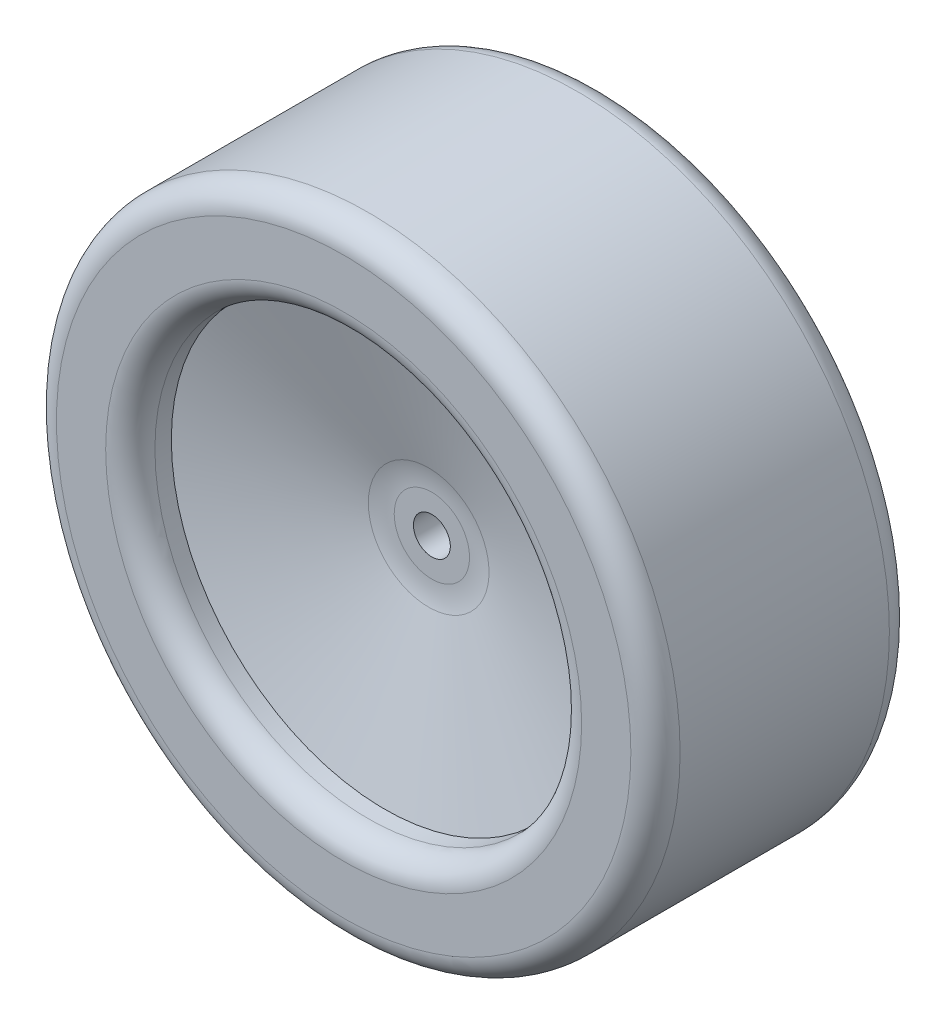
from build123d import *

# Parameters (mm, degrees)
CROQUIS2_R            = 2.25
CORTAR_EXTRUIR1_DEPTH = 21.75
REDONDEO1_R           = 3
REDONDEO2_R           = 10


with BuildPart() as part:
    # Croquis1 → Revolución4 (revolve)
    with BuildSketch(Plane(origin=(0, 0, 0), x_dir=(0, 0, -1), z_dir=(1, 0, 0))):
        Polygon((15.75, 38), (-15.75, 38), (-15.75, 26), (-10.75, 26), (-5, 6), (-5, 0), (5, 0), (5, 6), (10.75, 26), (15.75, 26), align=None)
    revolve(axis=Axis((0, 0, -5), (0, 0, 1)))

    # Croquis2 → Cortar-Extruir1 (cut, through all)
    with BuildSketch(Plane(origin=(0, 0, -5), x_dir=(-1, 0, 0), z_dir=(0, 0, -1))):
        Circle(CROQUIS2_R)
    extrude(amount=-CORTAR_EXTRUIR1_DEPTH, mode=Mode.SUBTRACT)

    # Redondeo1
    redondeo1_edges = [part.edges().sort_by_distance(p)[0] for p in [
        (0, -38, 15.75),
        (0, -26, 15.75),
        (0, -26, -15.75),
        (0, -38, -15.75),
    ]]
    fillet(redondeo1_edges, radius=REDONDEO1_R)

    # Redondeo2
    redondeo2_edges = [part.edges().sort_by_distance(p)[0] for p in [
        (0, -6, 5),
        (0, -6, -5),
    ]]
    fillet(redondeo2_edges, radius=REDONDEO2_R)


solid = part.part
